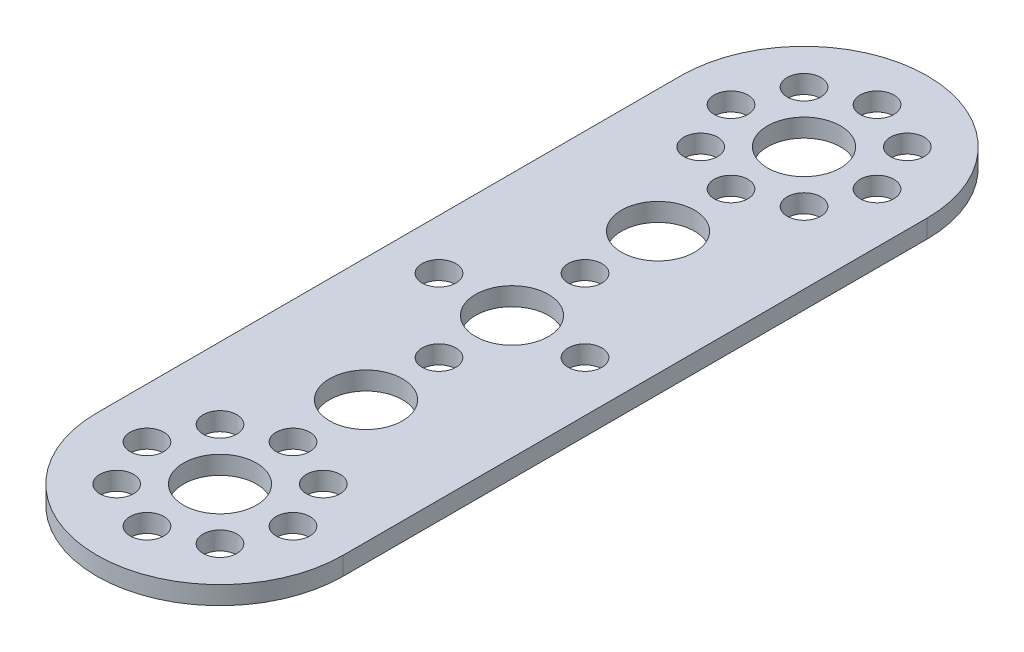
from build123d import *

# Parameters (mm, degrees)
EXTRUDE1_DEPTH = 2
SKETCH3_R      = 4
SKETCH3_R_2    = 1.85
EXTRUDE2_DEPTH = 2


with BuildPart() as part:
    # Sketch2 → Extrude1 (new body)
    with BuildSketch(Plane(origin=(0, 0, 0), x_dir=(1, 0, 0), z_dir=(0, 1, 0))):
        with BuildLine():
            Line((-13.5, -32), (-13.5, 32))
            ThreePointArc((-13.5, 32), (0, 45.5), (13.5, 32))
            Line((13.5, 32), (13.5, -32))
            ThreePointArc((13.5, -32), (0, -45.5), (-13.5, -32))
        make_face()
    extrude(amount=EXTRUDE1_DEPTH)

    # Sketch3 → Extrude2 (cut)
    with BuildSketch(Plane(origin=(0, 2, 0), x_dir=(1, 0, 0), z_dir=(0, 1, 0))):
        with Locations((0, -16)):
            Circle(SKETCH3_R)
        with Locations((0, 16)):
            Circle(SKETCH3_R)
        Circle(SKETCH3_R)
        with Locations((0, 8)):
            Circle(SKETCH3_R_2)
        with Locations((0, -8)):
            Circle(SKETCH3_R_2)
        with Locations((8, 0)):
            Circle(SKETCH3_R_2)
        with Locations((-8, 0)):
            Circle(SKETCH3_R_2)
        with Locations((0, -24)):
            Circle(SKETCH3_R_2)
        with Locations((8, -32)):
            Circle(SKETCH3_R_2)
        with Locations((0, -32)):
            Circle(SKETCH3_R)
        with Locations((-8, -32)):
            Circle(SKETCH3_R_2)
        with Locations((-5.66, -37.66)):
            Circle(SKETCH3_R_2)
        with Locations((5.66, -37.66)):
            Circle(SKETCH3_R_2)
        with Locations((0, -40)):
            Circle(SKETCH3_R_2)
        with Locations((-5.66, -26.34)):
            Circle(SKETCH3_R_2)
        with Locations((5.66, -26.34)):
            Circle(SKETCH3_R_2)
        with Locations((0, 40)):
            Circle(SKETCH3_R_2)
        with Locations((8, 32)):
            Circle(SKETCH3_R_2)
        with Locations((0, 32)):
            Circle(SKETCH3_R)
        with Locations((-8, 32)):
            Circle(SKETCH3_R_2)
        with Locations((-5.66, 26.34)):
            Circle(SKETCH3_R_2)
        with Locations((5.66, 26.34)):
            Circle(SKETCH3_R_2)
        with Locations((0, 24)):
            Circle(SKETCH3_R_2)
        with Locations((-5.66, 37.66)):
            Circle(SKETCH3_R_2)
        with Locations((5.66, 37.66)):
            Circle(SKETCH3_R_2)
    extrude(amount=-EXTRUDE2_DEPTH, mode=Mode.SUBTRACT)


solid = part.part
